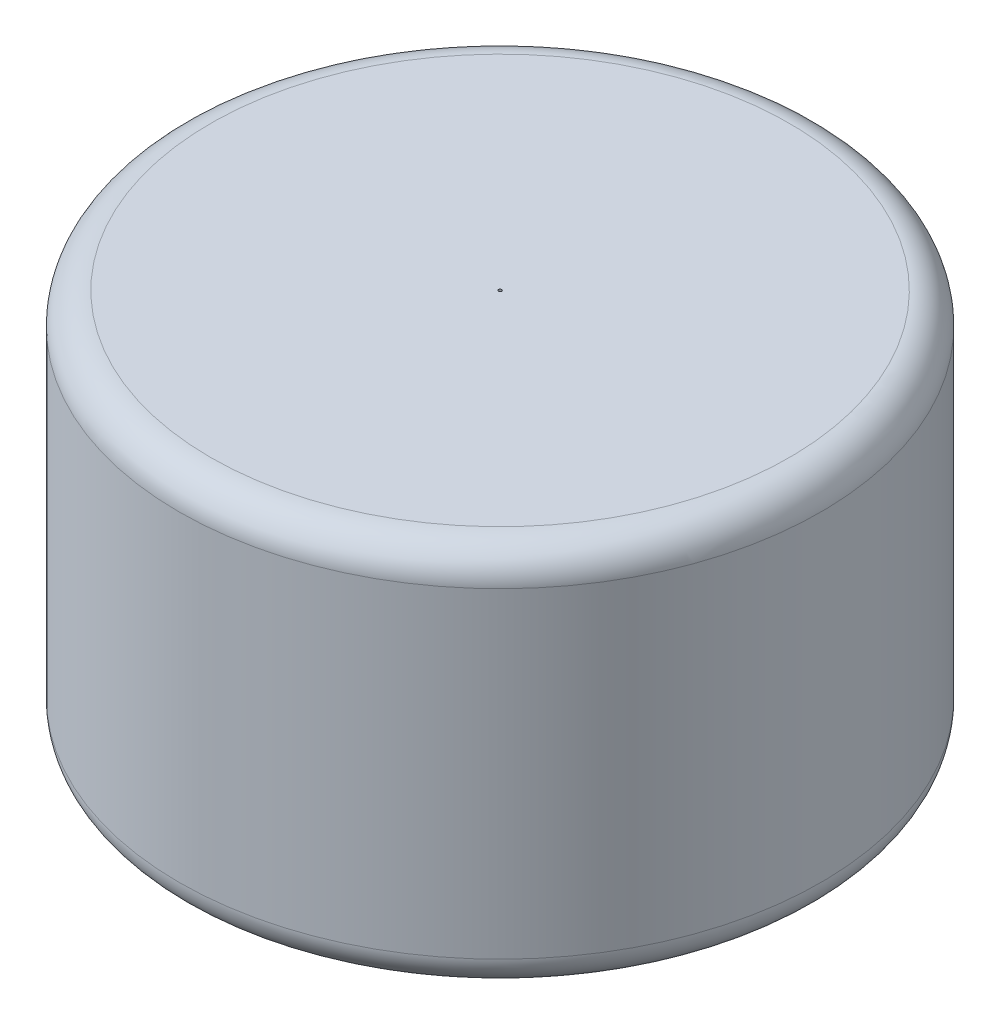
from build123d import *

# Parameters (mm, degrees)
SKETCH_1_R      = 51
EXTRUDE_1_DEPTH = 61
FILLET_1_R      = 5
SKETCH_6_W      = 41
SKETCH_6_H      = 41
SKETCH_7_W      = 0.25
SKETCH_7_H      = 45.977886119


with BuildPart() as part:
    # 草图1 → 凸台-拉伸1 (new body)
    with BuildSketch(Plane(origin=(0, 0, 0), x_dir=(1, 0, 0), z_dir=(0, 1, 0))):
        Circle(SKETCH_1_R)
    extrude(amount=EXTRUDE_1_DEPTH)

    # 圆角1
    fillet_1_edges = [part.edges().sort_by_distance(p)[0] for p in [
        (-51, 0, 0),
        (-51, 61, 0),
    ]]
    fillet(fillet_1_edges, radius=FILLET_1_R)

    # 草图6 → 切除-旋转4 (revolve, cut)
    with BuildSketch(Plane.XY):
        with Locations((20.5, 30.5)):
            Rectangle(SKETCH_6_W, SKETCH_6_H)
    revolve(axis=Axis((0, 0, 0), (0, 1, 0)), mode=Mode.SUBTRACT)

    # 草图7 → 切除-旋转5 (revolve, cut)
    with BuildSketch(Plane.XY):
        with Locations((-0.125, 38.011056941)):
            Rectangle(SKETCH_7_W, SKETCH_7_H)
    revolve(axis=Axis((0, 61, 0), (0, -1, 0)), mode=Mode.SUBTRACT)


solid = part.part
